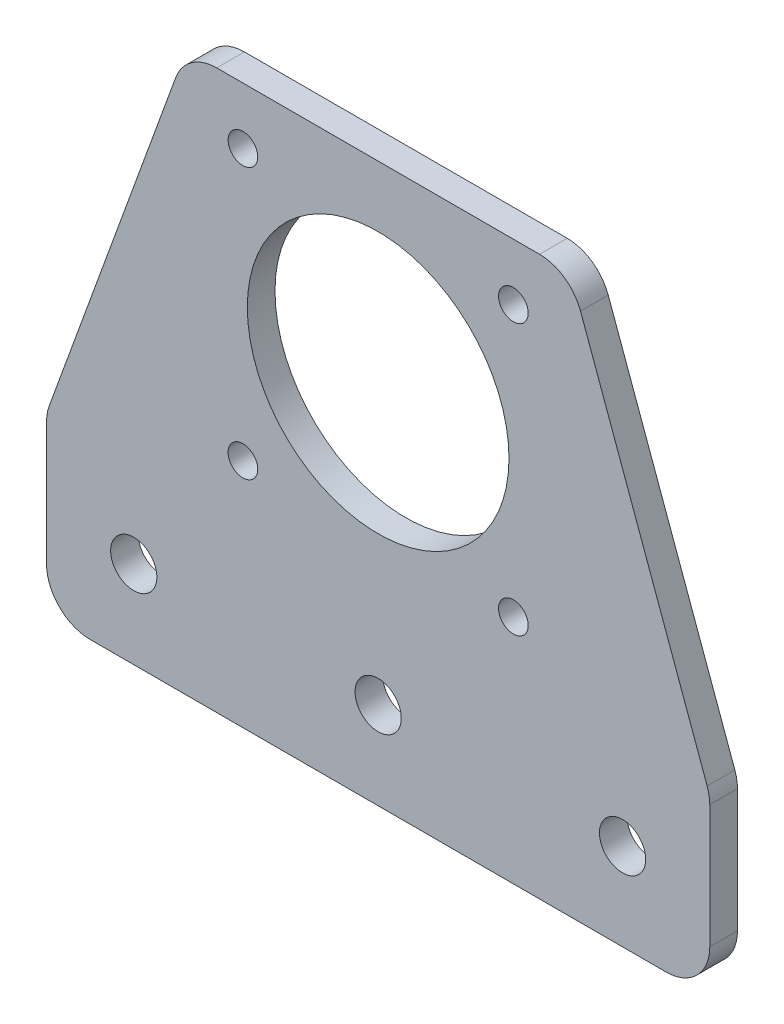
from build123d import *

# Parameters (mm, degrees)
SKETCH1_R           = 15
BOSS_EXTRUDE1_DEPTH = 3.175
SKETCH2_R           = 1.7
SKETCH2_R_2         = 2.65
CUT_EXTRUDE1_DEPTH  = 4.175
FILLET1_R           = 5


with BuildPart() as part:
    # Sketch1 → Boss-Extrude1 (new body)
    with BuildSketch(Plane.XY):
        Polygon((-22, 22), (22, 22), (38.014690308, -22), (38.014690308, -42), (-38.014690308, -42), (-38.014690308, -22), align=None)
        Circle(SKETCH1_R, mode=Mode.SUBTRACT)
    extrude(amount=BOSS_EXTRUDE1_DEPTH)

    # Sketch2 → Cut-Extrude1 (cut, through all)
    with BuildSketch(Plane.XY.offset(3.175)):
        with Locations((15.5, 15.5)):
            Circle(SKETCH2_R)
        with Locations((15.5, -15.5)):
            Circle(SKETCH2_R)
        with Locations((-15.5, -15.5)):
            Circle(SKETCH2_R)
        with Locations((-15.5, 15.5)):
            Circle(SKETCH2_R)
        with Locations((0, -32)):
            Circle(SKETCH2_R_2)
        with Locations((28.014690308, -32)):
            Circle(SKETCH2_R_2)
        with Locations((-28.014690308, -32)):
            Circle(SKETCH2_R_2)
    extrude(amount=-CUT_EXTRUDE1_DEPTH, mode=Mode.SUBTRACT)

    # Fillet1
    fillet1_edges = [part.edges().sort_by_distance(p)[0] for p in [
        (38.014690308, -22, 1.5875),
        (38.014690308, -42, 1.5875),
        (-38.014690308, -42, 1.5875),
        (-38.014690308, -22, 1.5875),
        (-22, 22, 1.5875),
        (22, 22, 1.5875),
    ]]
    fillet(fillet1_edges, radius=FILLET1_R)


solid = part.part
